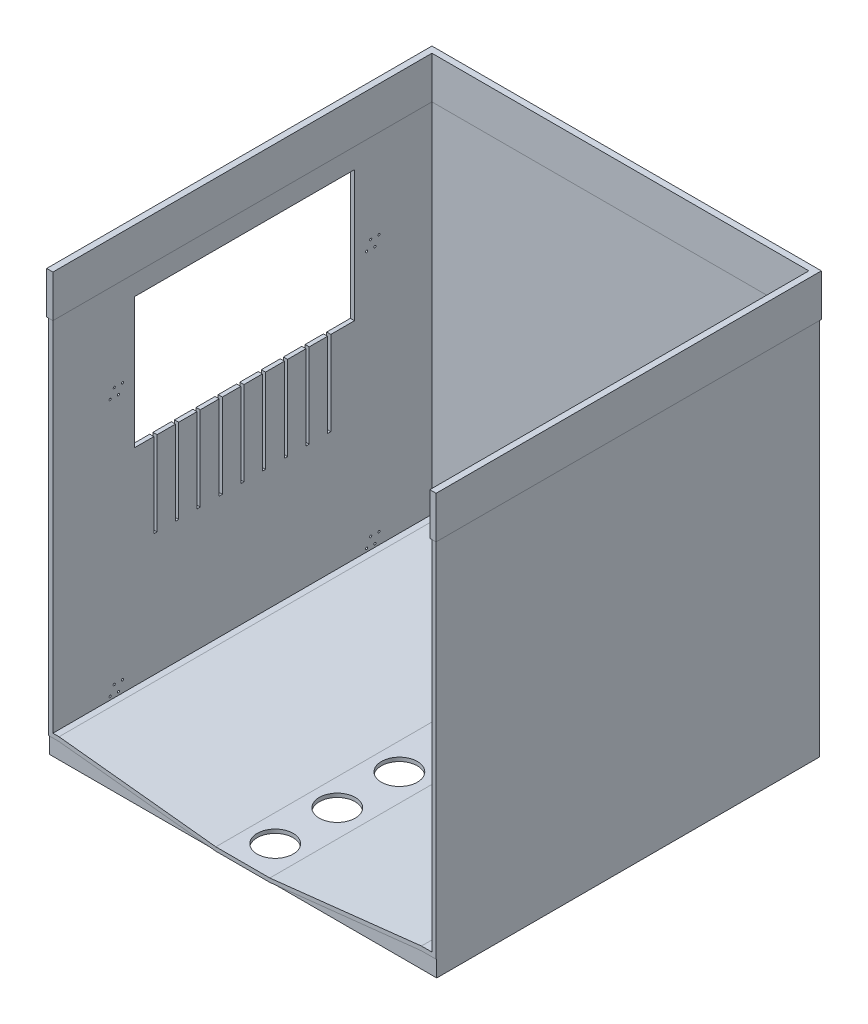
from build123d import *

# Parameters (mm, degrees)
SKETCH1_W           = 914.4
SKETCH1_H           = 914.4
BOSS_EXTRUDE1_DEPTH = 50
SKETCH2_W           = 914.4
SKETCH2_H           = 914.4
BOSS_EXTRUDE2_DEPTH = 10
SKETCH4_W           = 914.4
SKETCH4_H           = 914.4
BOSS_EXTRUDE3_DEPTH = 10
SKETCH5_W           = 934.4
SKETCH5_H           = 914.4
BOSS_EXTRUDE4_DEPTH = 10
CUT_EXTRUDE2_DEPTH  = 925.4
BOSS_EXTRUDE5_DEPTH = 10
SKETCH10_R          = 43.356897361
CUT_EXTRUDE3_DEPTH  = 10.220124983
SKETCH11_W          = 530.7
SKETCH11_H          = 315.6
CUT_EXTRUDE4_DEPTH  = 10
BOSS_EXTRUDE7_DEPTH = 101.6
BOSS_EXTRUDE8_DEPTH = 922.782
SKETCH17_R          = 2.5
CUT_EXTRUDE5_DEPTH  = 10
SKETCH18_W          = 7.62
SKETCH18_H          = 203.2
CUT_EXTRUDE6_DEPTH  = 10


with BuildPart() as part:
    # Sketch1 → Boss-Extrude1 (new body)
    with BuildSketch(Plane(origin=(0, 0, 0), x_dir=(1, 0, 0), z_dir=(0, 1, 0))):
        with Locations((2.50749543, -165.494698355)):
            Rectangle(SKETCH1_W, SKETCH1_H)
    extrude(amount=BOSS_EXTRUDE1_DEPTH)

    # Sketch2 → Boss-Extrude2 (add)
    with BuildSketch(Plane(origin=(459.70749543, 0, 0), x_dir=(0, 0, -1), z_dir=(1, 0, 0))):
        with Locations((-165.494698355, 457.2)):
            Rectangle(SKETCH2_W, SKETCH2_H)
    extrude(amount=BOSS_EXTRUDE2_DEPTH)

    # Sketch4 → Boss-Extrude3 (add)
    with BuildSketch(Plane.ZY.offset(454.69250457)):
        with Locations((165.494698355, 457.2)):
            Rectangle(SKETCH4_W, SKETCH4_H)
    extrude(amount=BOSS_EXTRUDE3_DEPTH)

    # Sketch5 → Boss-Extrude4 (add)
    with BuildSketch(Plane(origin=(0, 0, -291.705301645), x_dir=(-1, 0, 0), z_dir=(0, 0, -1))):
        with Locations((-2.50749543, 457.2)):
            Rectangle(SKETCH5_W, SKETCH5_H)
    extrude(amount=BOSS_EXTRUDE4_DEPTH)

    # Sketch6 → Cut-Extrude2 (cut, through all)
    with BuildSketch(Plane.XY.offset(622.694698355)):
        Polygon((-464.69250457, 0), (-61.618954828, 0), (-439.884510812, 40), (-464.69250457, 40), align=None)
        Polygon((-439.884510812, 50), (-61.618954828, 9.220124983), (68.644680345, 9.220124983), (434.384886793, 50), align=None)
        Polygon((434.384886793, 40), (68.644680345, 0), (469.70749543, 0), (469.70749543, 40), align=None)
    extrude(amount=-CUT_EXTRUDE2_DEPTH, mode=Mode.SUBTRACT)

    # Sketch8 → Boss-Extrude5 (add)
    with BuildSketch(Plane(origin=(0, 0, -301.705301645), x_dir=(-1, 0, 0), z_dir=(0, 0, -1))):
        Polygon((-434.384886793, 50), (-68.644680345, 9.220124983), (61.618954828, 9.220124983), (439.884510812, 50), align=None)
    extrude(amount=-BOSS_EXTRUDE5_DEPTH)

    # Sketch10 → Cut-Extrude3 (cut, through all)
    with BuildSketch(Plane(origin=(0, 9.220124983, 0), x_dir=(1, 0, 0), z_dir=(0, 1, 0))):
        with Locations((3.426978674, -544.581550471)):
            Circle(SKETCH10_R)
        with Locations((3.262056312, -394.581641136)):
            Circle(SKETCH10_R)
        with Locations((3.097133949, -244.5817318)):
            Circle(SKETCH10_R)
        with Locations((2.932211587, -94.581822465)):
            Circle(SKETCH10_R)
        with Locations((2.767289224, 55.41808687)):
            Circle(SKETCH10_R)
        with Locations((2.602366862, 205.417996206)):
            Circle(SKETCH10_R)
    extrude(amount=-CUT_EXTRUDE3_DEPTH, mode=Mode.SUBTRACT)

    # Sketch11 → Cut-Extrude4 (cut)
    with BuildSketch(Plane.ZY.offset(464.69250457)):
        with Locations((160.494698355, 705.8)):
            Rectangle(SKETCH11_W, SKETCH11_H)
    extrude(amount=-CUT_EXTRUDE4_DEPTH, mode=Mode.SUBTRACT)

    # Sketch14 → Boss-Extrude7 (add)
    with BuildSketch(Plane(origin=(0, 914.4, 0), x_dir=(1, 0, 0), z_dir=(0, 1, 0))):
        Polygon((457.16749543, 289.165301645), (457.16749543, -625.234698355), (472.24749543, -625.234698355), (472.24749543, 304.245301645), (-467.23250457, 304.245301645), (-467.23250457, -625.234698355), (-452.15250457, -625.234698355), (-452.15250457, 289.165301645), align=None)
    extrude(amount=BOSS_EXTRUDE7_DEPTH)

    # Sketch16 → Boss-Extrude8 (add)
    with BuildSketch(Plane(origin=(0, 0, -301.705301645), x_dir=(-1, 0, 0), z_dir=(0, 0, -1))):
        Polygon((-469.70749543, 40), (-469.70749543, 0), (-68.644680345, 0), (-434.384886793, 40), align=None)
        Polygon((61.618954828, 0), (439.884510812, 40), (464.69250457, 40), (464.69250457, 0), align=None)
    extrude(amount=-BOSS_EXTRUDE8_DEPTH)

    # Sketch17 → Cut-Extrude5 (cut)
    with BuildSketch(Plane.ZY.offset(464.69250457)):
        with Locations((-164.105301645, 77.736709547)):
            Circle(SKETCH17_R)
        with Locations((-144.105301645, 77.736709547)):
            Circle(SKETCH17_R)
        with Locations((-134.105301645, 57.736709547)):
            Circle(SKETCH17_R)
        with Locations((-154.105301645, 57.736709547)):
            Circle(SKETCH17_R)
        with Locations((474.694698355, 77.736709547)):
            Circle(SKETCH17_R)
        with Locations((484.694698355, 57.736709547)):
            Circle(SKETCH17_R)
        with Locations((464.694698355, 57.736709547)):
            Circle(SKETCH17_R)
        with Locations((454.694698355, 77.736709547)):
            Circle(SKETCH17_R)
        with Locations((-164.105301645, 698.149833047)):
            Circle(SKETCH17_R)
        with Locations((-144.105301645, 698.149833047)):
            Circle(SKETCH17_R)
        with Locations((-134.105301645, 678.149833047)):
            Circle(SKETCH17_R)
        with Locations((-154.105301645, 678.149833047)):
            Circle(SKETCH17_R)
        with Locations((474.694698355, 698.149833047)):
            Circle(SKETCH17_R)
        with Locations((484.694698355, 678.149833047)):
            Circle(SKETCH17_R)
        with Locations((464.694698355, 678.149833047)):
            Circle(SKETCH17_R)
        with Locations((454.694698355, 698.149833047)):
            Circle(SKETCH17_R)
    extrude(amount=-CUT_EXTRUDE5_DEPTH, mode=Mode.SUBTRACT)

    # Sketch18 → Cut-Extrude6 (cut)
    with BuildSketch(Plane.ZY.offset(464.69250457)):
        with Locations((-43.895301645, 446.4)):
            Rectangle(SKETCH18_W, SKETCH18_H)
        with Locations((8.174698355, 446.4)):
            Rectangle(SKETCH18_W, SKETCH18_H)
        with Locations((60.244698355, 446.4)):
            Rectangle(SKETCH18_W, SKETCH18_H)
        with Locations((113.584698355, 446.4)):
            Rectangle(SKETCH18_W, SKETCH18_H)
        with Locations((165.654698355, 446.4)):
            Rectangle(SKETCH18_W, SKETCH18_H)
        with Locations((217.724698355, 446.4)):
            Rectangle(SKETCH18_W, SKETCH18_H)
        with Locations((271.064698355, 446.4)):
            Rectangle(SKETCH18_W, SKETCH18_H)
        with Locations((323.134698355, 446.4)):
            Rectangle(SKETCH18_W, SKETCH18_H)
        with Locations((375.204698355, 446.4)):
            Rectangle(SKETCH18_W, SKETCH18_H)
    extrude(amount=-CUT_EXTRUDE6_DEPTH, mode=Mode.SUBTRACT)


solid = part.part
